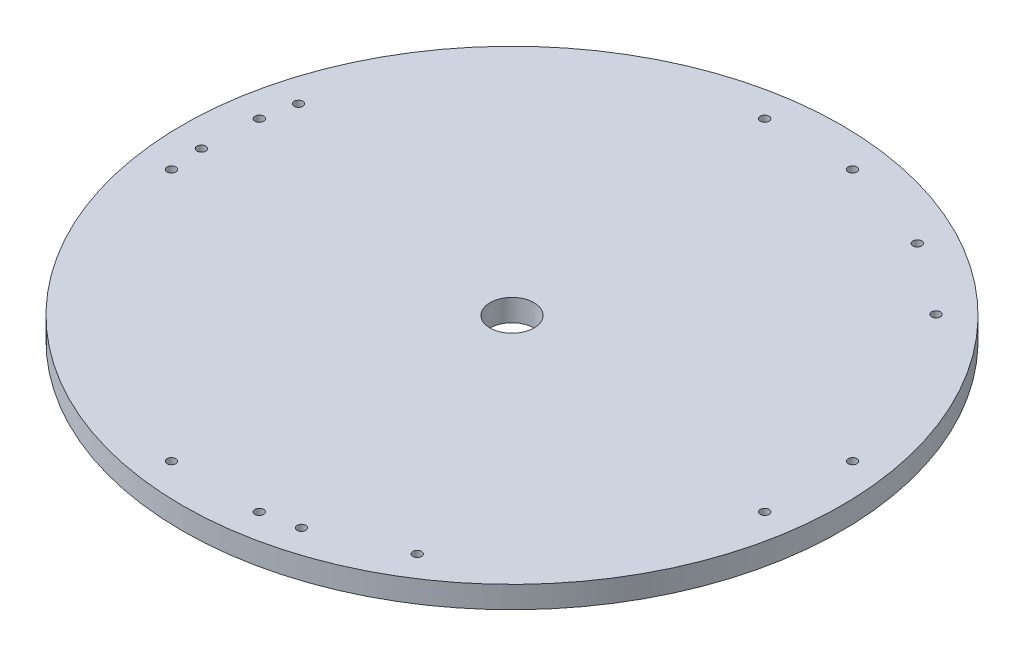
from build123d import *

# Parameters (mm, degrees)
SKETCH_1_R      = 150
SKETCH_1_R_2    = 2
SKETCH_1_R_3    = 10
EXTRUDE_1_DEPTH = 10


with BuildPart() as part:
    # 草圖1 → 填料-伸長1 (new body)
    with BuildSketch(Plane(origin=(0, 0, 0), x_dir=(1, 0, 0), z_dir=(0, 1, 0))):
        Circle(SKETCH_1_R)
        with Locations((-20, 135)):
            Circle(SKETCH_1_R_2, mode=Mode.SUBTRACT)
        with Locations((20, 135)):
            Circle(SKETCH_1_R_2, mode=Mode.SUBTRACT)
        with Locations((135, 20)):
            Circle(SKETCH_1_R_2, mode=Mode.SUBTRACT)
        with Locations((135, -20)):
            Circle(SKETCH_1_R_2, mode=Mode.SUBTRACT)
        with Locations((20, -135)):
            Circle(SKETCH_1_R_2, mode=Mode.SUBTRACT)
        with Locations((-20, -135)):
            Circle(SKETCH_1_R_2, mode=Mode.SUBTRACT)
        with Locations((-135, -20)):
            Circle(SKETCH_1_R_2, mode=Mode.SUBTRACT)
        with Locations((-135, 20)):
            Circle(SKETCH_1_R_2, mode=Mode.SUBTRACT)
        Circle(SKETCH_1_R_3, mode=Mode.SUBTRACT)
        with Locations((63.889953207, 120.594667707)):
            Circle(SKETCH_1_R_2, mode=Mode.SUBTRACT)
        with Locations((96.110046793, 96.890964003)):
            Circle(SKETCH_1_R_2, mode=Mode.SUBTRACT)
        with Locations((72.493069191, -115.627656377)):
            Circle(SKETCH_1_R_2, mode=Mode.SUBTRACT)
        with Locations((35.855012827, -131.679224083)):
            Circle(SKETCH_1_R_2, mode=Mode.SUBTRACT)
        with Locations((-136.383022398, -4.96701133)):
            Circle(SKETCH_1_R_2, mode=Mode.SUBTRACT)
        with Locations((-131.96505962, 34.78826008)):
            Circle(SKETCH_1_R_2, mode=Mode.SUBTRACT)
    extrude(amount=EXTRUDE_1_DEPTH)


solid = part.part
